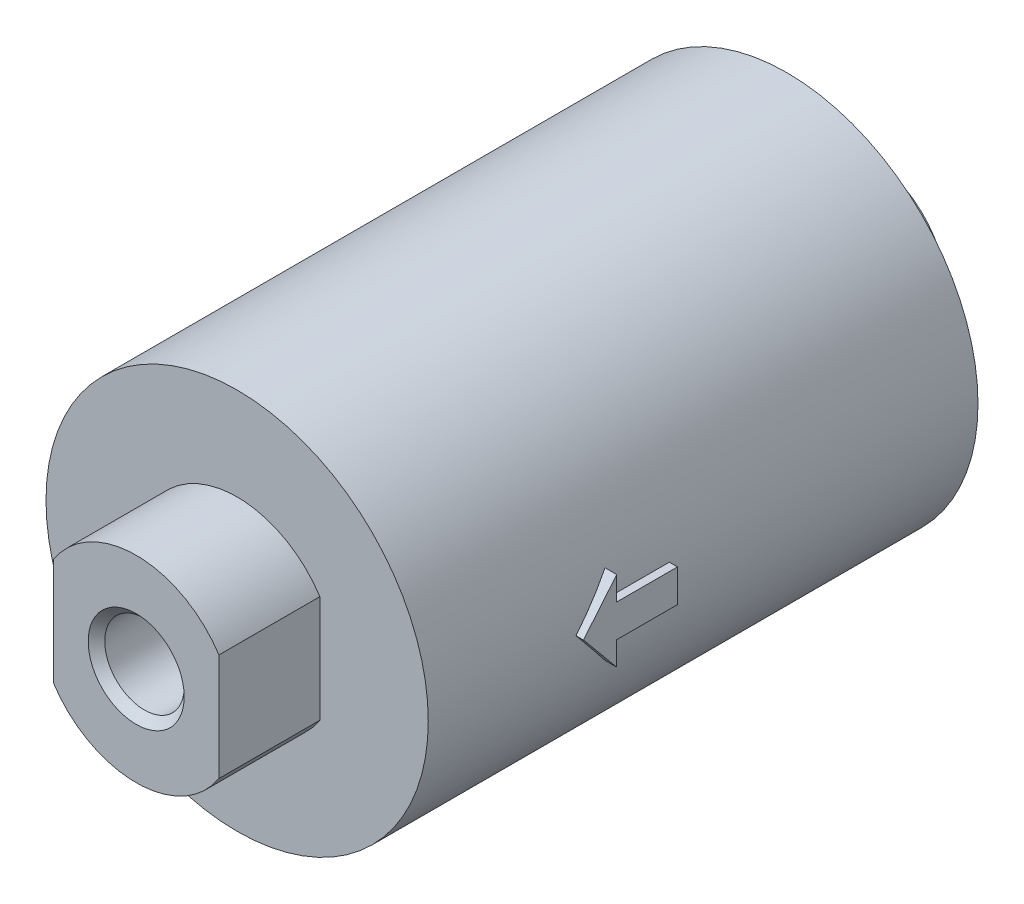
from build123d import *

# Parameters (mm, degrees)
SKETCH1_R           = 11.55
BOSS_EXTRUDE1_DEPTH = 33.22
BOSS_EXTRUDE2_DEPTH = 6.1
SKETCH3_R           = 2.4
CUT_EXTRUDE1_DEPTH  = 8.3
CHAMFER1_SIZE       = 0.5
SKETCH4_R           = 2.45
BOSS_EXTRUDE3_DEPTH = 4.7
BOSS_EXTRUDE4_START = 6.793009
BOSS_EXTRUDE4_DEPTH = 0.706991


with BuildPart() as part:
    # Sketch1 → Boss-Extrude1 (new body)
    with BuildSketch(Plane.XY):
        Circle(SKETCH1_R)
    extrude(amount=BOSS_EXTRUDE1_DEPTH)

    # Sketch2 → Boss-Extrude2 (add)
    with BuildSketch(Plane.XY.offset(33.22)):
        with BuildLine():
            Line((5, 3.234505372), (5, -3.234505372))
            ThreePointArc((5, -3.234505372), (0, -5.955), (-5, -3.234505372))
            Line((-5, -3.234505372), (-5, 3.234505372))
            ThreePointArc((-5, 3.234505372), (0, 5.955), (5, 3.234505372))
        make_face()
    extrude(amount=BOSS_EXTRUDE2_DEPTH)

    # Sketch3 → Cut-Extrude1 (cut)
    with BuildSketch(Plane.XY.offset(39.32)):
        Circle(SKETCH3_R)
    extrude(amount=-CUT_EXTRUDE1_DEPTH, mode=Mode.SUBTRACT)

    # Chamfer1
    chamfer1_edges = [part.edges().sort_by_distance(p)[0] for p in [
        (-2.4, 0, 39.32),
    ]]
    chamfer(chamfer1_edges, length=CHAMFER1_SIZE)

    # Sketch4 → Boss-Extrude3 (add)
    with BuildSketch(Plane(origin=(0, 0, 0), x_dir=(-1, 0, 0), z_dir=(0, 0, -1))):
        with BuildLine():
            Line((4.5, 2.179449472), (4.5, -2.179449472))
            ThreePointArc((4.5, -2.179449472), (0, -5), (-4.5, -2.179449472))
            Line((-4.5, -2.179449472), (-4.5, 2.179449472))
            ThreePointArc((-4.5, 2.179449472), (0, 5), (4.5, 2.179449472))
        make_face()
        Circle(SKETCH4_R, mode=Mode.SUBTRACT)
    extrude(amount=BOSS_EXTRUDE3_DEPTH)

    # Sketch5 → Boss-Extrude4 (add)
    with BuildSketch(Plane(origin=(4.5, 0, 0), x_dir=(0, 0, -1), z_dir=(1, 0, 0)).offset(BOSS_EXTRUDE4_START)):
        Polygon((-24.291547622, 0), (-22.281436224, 2.422902131), (-22.281436224, 0.987108276), (-18.60765225, 0.987108276), (-18.60765225, -0.987108276), (-22.281436224, -0.987108276), (-22.281436224, -2.422902131), align=None)
    extrude(amount=BOSS_EXTRUDE4_DEPTH)


solid = part.part
